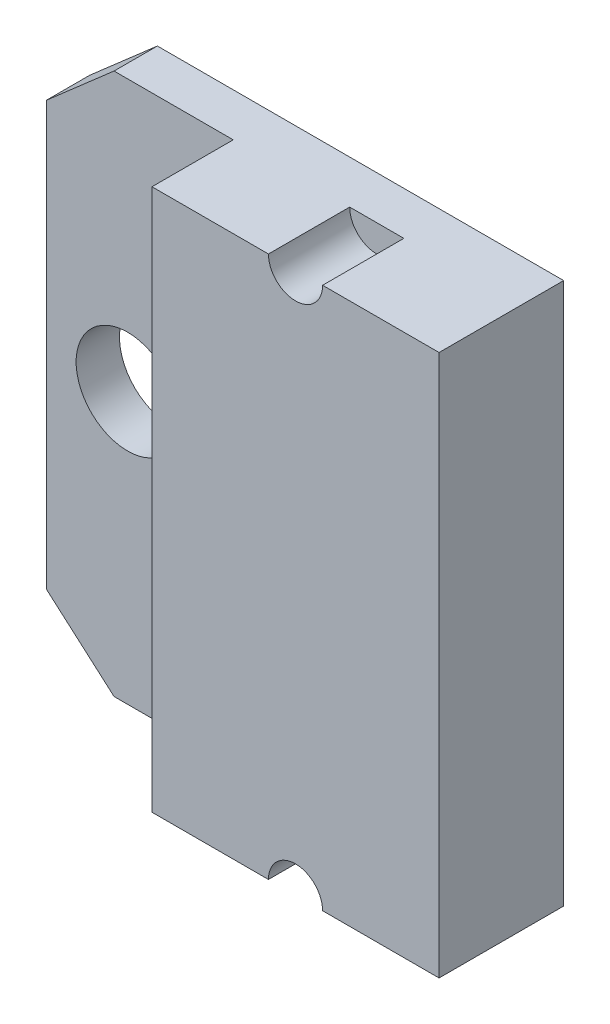
from build123d import *

# Parameters (mm, degrees)
SKETCH1_R           = 1.9
BOSS_EXTRUDE1_DEPTH = 1.6
SKETCH2_W           = 10.6
SKETCH2_H           = 20
BOSS_EXTRUDE2_DEPTH = 3
SKETCH4_R           = 1
CUT_EXTRUDE1_DEPTH  = 3


with BuildPart() as part:
    # Sketch1 → Boss-Extrude1 (new body)
    with BuildSketch(Plane.XY):
        Polygon((-7.5, 6.464954653), (-5, 8.65), (10, 8.65), (10, -11.35), (-5, -11.35), (-7.5, -9.164954653), align=None)
        with Locations((-4.5, -1.35)):
            Circle(SKETCH1_R, mode=Mode.SUBTRACT)
    extrude(amount=BOSS_EXTRUDE1_DEPTH)

    # Sketch2 → Boss-Extrude2 (add)
    with BuildSketch(Plane.XY.offset(1.6)):
        with Locations((4.7, -1.35)):
            Rectangle(SKETCH2_W, SKETCH2_H)
    extrude(amount=BOSS_EXTRUDE2_DEPTH)

    # Sketch4 → Cut-Extrude1 (cut)
    with BuildSketch(Plane.XY.offset(4.6)):
        with Locations((4.7, -11.35)):
            Circle(SKETCH4_R)
        with Locations((4.7, 8.65)):
            Circle(SKETCH4_R)
    extrude(amount=-CUT_EXTRUDE1_DEPTH, mode=Mode.SUBTRACT)


solid = part.part
